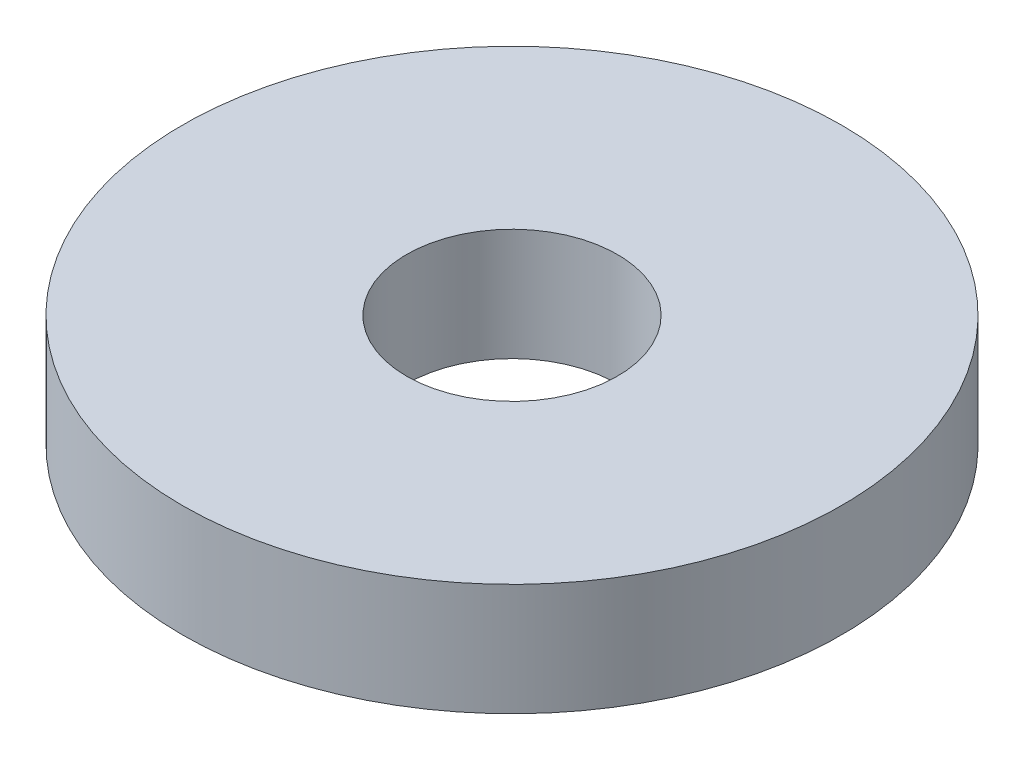
from build123d import *

# Parameters (mm, degrees)
SKETCH1_R           = 5
SKETCH1_R_2         = 1.6
BOSS_EXTRUDE1_DEPTH = 1.7


with BuildPart() as part:
    # Sketch1 → Boss-Extrude1 (new body)
    with BuildSketch(Plane(origin=(0, 0, 0), x_dir=(1, 0, 0), z_dir=(0, 1, 0))):
        Circle(SKETCH1_R)
        Circle(SKETCH1_R_2, mode=Mode.SUBTRACT)
    extrude(amount=BOSS_EXTRUDE1_DEPTH)


solid = part.part
